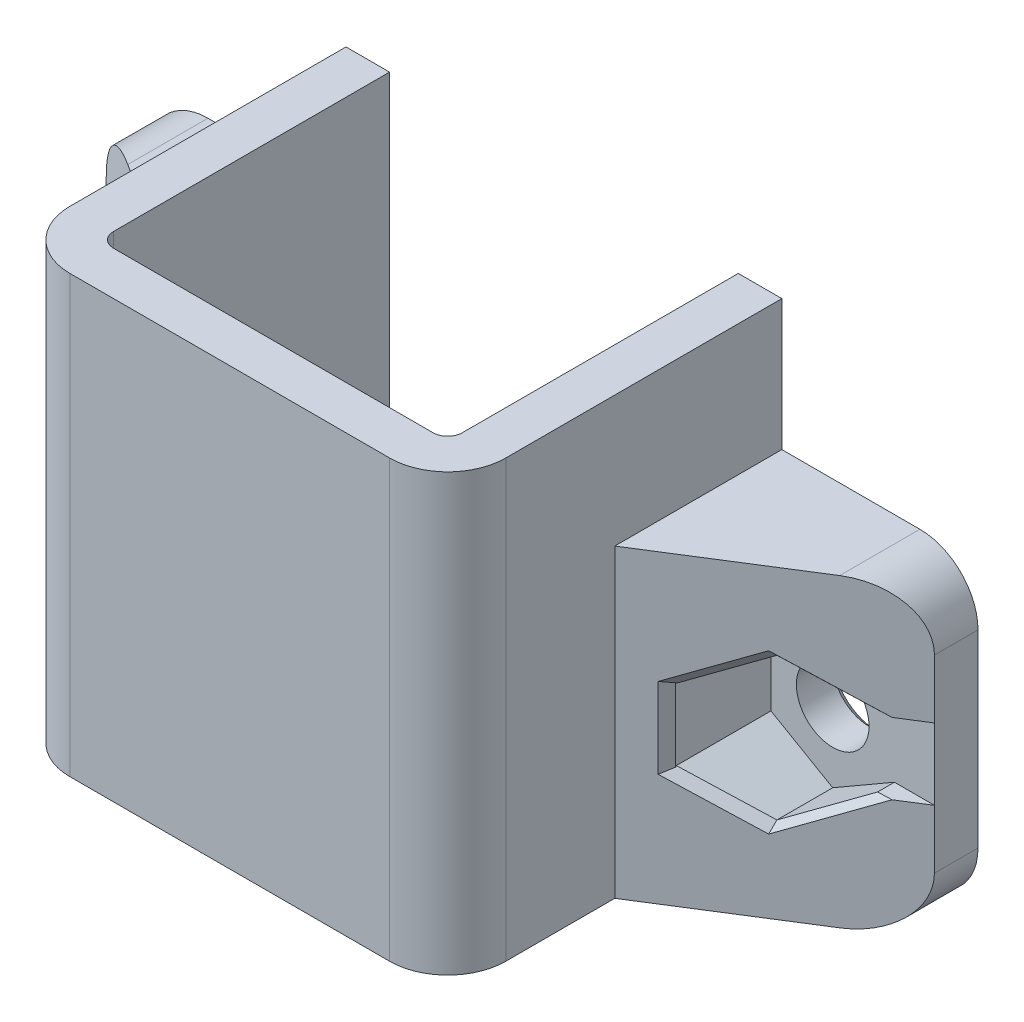
from build123d import *

# Parameters (mm, degrees)
ESQUISSE1_W             = 15
ESQUISSE1_H             = 15
BOSS_EXTRU_1_DEPTH      = 11.5
ESQUISSE2_W             = 12
ESQUISSE2_H             = 15
ENL_V_MAT_EXTRU_1_DEPTH = 10
CONG_1_R                = 2
ESQUISSE3_W             = 0.5
ESQUISSE3_H             = 6
BOSS_EXTRU_2_DEPTH      = 0.5
ENL_V_MAT_EXTRU_2_DEPTH = 6
ESQUISSE5_W             = 3.5
ESQUISSE5_H             = 4
ESQUISSE5_H_2           = 2
BOSS_EXTRU_3_DEPTH      = 0.4
ESQUISSE6_W             = 0.4
ESQUISSE6_H             = 4
ESQUISSE6_H_2           = 2
BOSS_EXTRU_4_DEPTH      = 3.1
CONG_3_R                = 0.5
ESQUISSE7_W             = 6.75
ESQUISSE7_H             = 10.5
BOSS_EXTRU_5_DEPTH      = 1.5
ESQUISSE12_R            = 1.25
ENL_V_MAT_EXTRU_6_DEPTH = 1.5
BOSS_EXTRU_6_DEPTH      = 4.25
ENL_V_MAT_EXTRU_7_DEPTH = 10.5
CONG_5_R                = 2
CHANFREIN2_SIZE         = 0.25
CHANFREIN3_SIZE         = 0.25
CHANFREIN4_SIZE         = 0.25


with BuildPart() as part:
    # Esquisse1 → Boss.-Extru.1 (new body)
    with BuildSketch(Plane.XY):
        Rectangle(ESQUISSE1_W, ESQUISSE1_H)
    extrude(amount=BOSS_EXTRU_1_DEPTH)

    # Esquisse2 → Enlèv. mat.-Extru.1 (cut)
    with BuildSketch(Plane(origin=(0, 0, 0), x_dir=(-1, 0, 0), z_dir=(0, 0, -1))):
        Rectangle(ESQUISSE2_W, ESQUISSE2_H)
    extrude(amount=-ENL_V_MAT_EXTRU_1_DEPTH, mode=Mode.SUBTRACT)

    # Congé1
    cong_1_edges = [part.edges().sort_by_distance(p)[0] for p in [
        (-7.5, 0, 11.5),
        (7.5, 0, 11.5),
    ]]
    fillet(cong_1_edges, radius=CONG_1_R)

    # Esquisse3 → Boss.-Extru.2 (add)
    with BuildSketch(Plane(origin=(0, 0, 10), x_dir=(-1, 0, 0), z_dir=(0, 0, -1))):
        with Locations((-5.75, 4.5)):
            Rectangle(ESQUISSE3_W, ESQUISSE3_H)
        with Locations((5.75, 4.5)):
            Rectangle(ESQUISSE3_W, ESQUISSE3_H)
    extrude(amount=BOSS_EXTRU_2_DEPTH)

    # Esquisse4 → Enlèv. mat.-Extru.2 (cut)
    with BuildSketch(Plane.XZ.offset(-1.5)):
        with BuildLine():
            Line((-6, 9.5), (-5.5, 9.5))
            Line((-5.5, 9.5), (-5.5, 10))
            ThreePointArc((-5.5, 10), (-5.853553391, 9.853553391), (-6, 9.5))
        make_face()
        with BuildLine():
            Line((6, 9.5), (5.5, 9.5))
            Line((5.5, 9.5), (5.5, 10))
            ThreePointArc((5.5, 10), (5.853553391, 9.853553391), (6, 9.5))
        make_face()
    extrude(amount=-ENL_V_MAT_EXTRU_2_DEPTH, mode=Mode.SUBTRACT)

    # Esquisse5 → Boss.-Extru.3 (add)
    with BuildSketch(Plane(origin=(0, 0, 10), x_dir=(-1, 0, 0), z_dir=(0, 0, -1))):
        with Locations((-4.25, -4.5)):
            Rectangle(ESQUISSE5_W, ESQUISSE5_H)
        with Locations((-4.25, -0.5)):
            Rectangle(ESQUISSE5_W, ESQUISSE5_H_2)
    extrude(amount=BOSS_EXTRU_3_DEPTH)

    # Esquisse6 → Boss.-Extru.4 (add)
    with BuildSketch(Plane(origin=(0, 0, 9.6), x_dir=(-1, 0, 0), z_dir=(0, 0, -1))):
        with Locations((-5.8, -4.5)):
            Rectangle(ESQUISSE6_W, ESQUISSE6_H)
        with Locations((-5.8, -0.5)):
            Rectangle(ESQUISSE6_W, ESQUISSE6_H_2)
    extrude(amount=BOSS_EXTRU_4_DEPTH)

    # Congé3
    cong_3_edges = [part.edges().sort_by_distance(p)[0] for p in [
        (5.6, -4.5, 9.6),
        (5.6, -0.5, 9.6),
    ]]
    fillet(cong_3_edges, radius=CONG_3_R)

    # Esquisse7 → Boss.-Extru.5 (add)
    with BuildSketch(Plane(origin=(0, 0, 0), x_dir=(-1, 0, 0), z_dir=(0, 0, -1))):
        with Locations((-10.875, -2.25)):
            Rectangle(ESQUISSE7_W, ESQUISSE7_H)
        with Locations((10.875, -2.25)):
            Rectangle(ESQUISSE7_W, ESQUISSE7_H)
    extrude(amount=-BOSS_EXTRU_5_DEPTH)

    # Esquisse12 → Enlèv. mat.-Extru.6 (cut)
    with BuildSketch(Plane(origin=(0, 0, 0), x_dir=(-1, 0, 0), z_dir=(0, 0, -1))):
        with Locations((10.75, -2.25)):
            Circle(ESQUISSE12_R)
        with Locations((-10.75, -2.25)):
            Circle(ESQUISSE12_R)
    extrude(amount=-ENL_V_MAT_EXTRU_6_DEPTH, mode=Mode.SUBTRACT)

    # Esquisse13 → Boss.-Extru.6 (add)
    with BuildSketch(Plane.XY.offset(1.5)):
        Polygon((-7.5, 3), (-7.5, -7.5), (-14.25, -7.5), (-14.25, -3.342912687), (-13.107019699, -3.342912687), (-10.75, -4.703738644), (-8.625, -3.476869322), (-8.625, -1.023130678), (-10.75, 0.203738644), (-13.107019699, -1.157087313), (-14.25, -1.157087313), (-14.25, 3), align=None)
        Polygon((7.5, -7.5), (7.5, 3), (14.25, 3), (14.25, -1.023130678), (12.875, -1.023130678), (10.75, 0.203738644), (8.625, -1.023130678), (8.625, -3.476869322), (10.75, -4.703738644), (12.875, -3.476869322), (14.25, -3.476869322), (14.25, -7.5), align=None)
    extrude(amount=BOSS_EXTRU_6_DEPTH)

    # Esquisse14 → Enlèv. mat.-Extru.7 (cut)
    with BuildSketch(Plane.XZ.offset(7.5)):
        Polygon((-7.5, 5.75), (-14.25, 1.5), (-14.25, 5.75), align=None)
        Polygon((7.5, 5.75), (14.25, 1.5), (14.25, 5.75), align=None)
    extrude(amount=-ENL_V_MAT_EXTRU_7_DEPTH, mode=Mode.SUBTRACT)

    # Congé5
    cong_5_edges = [part.edges().sort_by_distance(p)[0] for p in [
        (-14.25, -7.5, 0.75),
        (-14.25, 3, 0.75),
        (14.25, 3, 0.75),
        (14.25, -7.5, 0.75),
    ]]
    fillet(cong_5_edges, radius=CONG_5_R)

    # Chanfrein2
    chanfrein2_edges = [part.edges().sort_by_distance(p)[0] for p in [
        (-11.928509849, -4.023325665, 2.961678984),
        (-9.6875, -4.090303983, 4.372685185),
        (-8.625, -2.25, 5.041666667),
        (-9.6875, -0.409696017, 4.372685185),
        (-11.928509849, -0.476674335, 2.961678984),
        (11.8125, -0.409696017, 3.034722222),
        (9.6875, -0.409696017, 4.372685185),
        (8.625, -2.25, 5.041666667),
        (9.6875, -4.090303983, 4.372685185),
        (11.8125, -4.090303983, 3.034722222),
    ]]
    chamfer(chanfrein2_edges, length=CHANFREIN2_SIZE)

    # Chanfrein3
    chanfrein3_edges = [part.edges().sort_by_distance(p)[0] for p in [
        (-9.5, -2.25, 0),
        (12, -2.25, 0),
    ]]
    chamfer(chanfrein3_edges, length=CHANFREIN3_SIZE)

    # Chanfrein4
    chanfrein4_edges = [part.edges().sort_by_distance(p)[0] for p in [
        (3.8, 0.5, 9.6),
        (5.6, -6.5, 7.8),
        (5.6, -2.5, 7.8),
        (5.6, -1.5, 7.8),
        (5.6, 0.5, 7.8),
        (3.8, -1.5, 9.6),
        (3.8, -6.5, 9.6),
        (5.453553391, 0.5, 9.453553391),
        (5.453553391, -1.5, 9.453553391),
        (5.453553391, -2.5, 9.453553391),
        (5.453553391, -6.5, 9.453553391),
        (3.8, -2.5, 9.6),
    ]]
    chamfer(chanfrein4_edges, length=CHANFREIN4_SIZE)


solid = part.part
